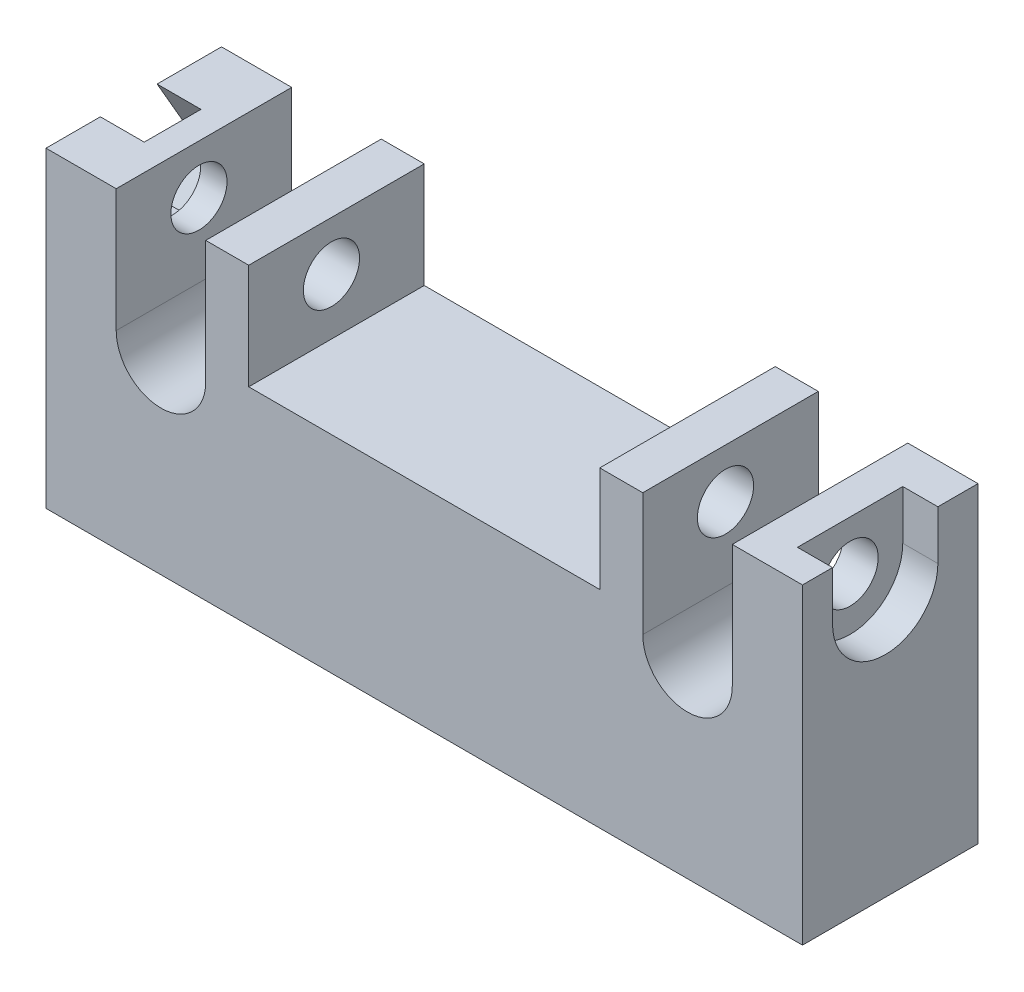
from build123d import *

# Parameters (mm, degrees)
BOSS_EXTRUDE1_DEPTH = 10
SKETCH2_R           = 1.6
CUT_EXTRUDE1_DEPTH  = 44.1
CUT_EXTRUDE2_DEPTH  = 2
CUT_EXTRUDE3_DEPTH  = 2.5
SKETCH6_W           = 20
SKETCH6_H           = 6
CUT_EXTRUDE4_DEPTH  = 11


with BuildPart() as part:
    # Sketch1 → Boss-Extrude1 (new body)
    with BuildSketch(Plane.XY):
        with BuildLine():
            Line((-21.55, 7.2), (-17.55, 7.2))
            Line((-17.55, 7.2), (-17.55, 0.2))
            ThreePointArc((-17.55, 0.2), (-15, -2.35), (-12.45, 0.2))
            Line((-12.45, 0.2), (-12.45, 7.2))
            Line((-12.45, 7.2), (12.45, 7.2))
            Line((12.45, 7.2), (12.45, 0.2))
            ThreePointArc((12.45, 0.2), (15, -2.35), (17.55, 0.2))
            Line((17.55, 0.2), (17.55, 7.2))
            Line((17.55, 7.2), (21.55, 7.2))
            Line((21.55, 7.2), (21.55, -10.574417152))
            Line((21.55, -10.574417152), (-21.55, -10.574417152))
            Line((-21.55, -10.574417152), (-21.55, 7.2))
        make_face()
    extrude(amount=BOSS_EXTRUDE1_DEPTH)

    # Sketch2 → Cut-Extrude1 (cut, through all)
    with BuildSketch(Plane(origin=(21.55, 0, 0), x_dir=(0, 0, -1), z_dir=(1, 0, 0))):
        with Locations((-5.28643622, 4.4)):
            Circle(SKETCH2_R)
    extrude(amount=-CUT_EXTRUDE1_DEPTH, mode=Mode.SUBTRACT)

    # Sketch3 → Cut-Extrude2 (cut)
    with BuildSketch(Plane(origin=(21.55, 0, 0), x_dir=(0, 0, -1), z_dir=(1, 0, 0))):
        with BuildLine():
            Line((-8.28643622, 7.2), (-2.28643622, 7.2))
            Line((-2.28643622, 7.2), (-2.28643622, 4.4))
            ThreePointArc((-2.28643622, 4.4), (-5.28643622, 1.4), (-8.28643622, 4.4))
            Line((-8.28643622, 4.4), (-8.28643622, 7.2))
        make_face()
    extrude(amount=-CUT_EXTRUDE2_DEPTH, mode=Mode.SUBTRACT)

    # Sketch4 → Cut-Extrude3 (cut)
    with BuildSketch(Plane.ZY.offset(21.55)):
        Polygon((8.519597728, 4.4), (6.903016974, 7.2), (3.669855466, 7.2), (2.053274713, 4.4), (3.669855466, 1.6), (6.903016974, 1.6), align=None)
    extrude(amount=-CUT_EXTRUDE3_DEPTH, mode=Mode.SUBTRACT)

    # Sketch6 → Cut-Extrude4 (cut, through all)
    with BuildSketch(Plane.XY.offset(10)):
        with Locations((0, 4.2)):
            Rectangle(SKETCH6_W, SKETCH6_H)
    extrude(amount=-CUT_EXTRUDE4_DEPTH, mode=Mode.SUBTRACT)


solid = part.part
